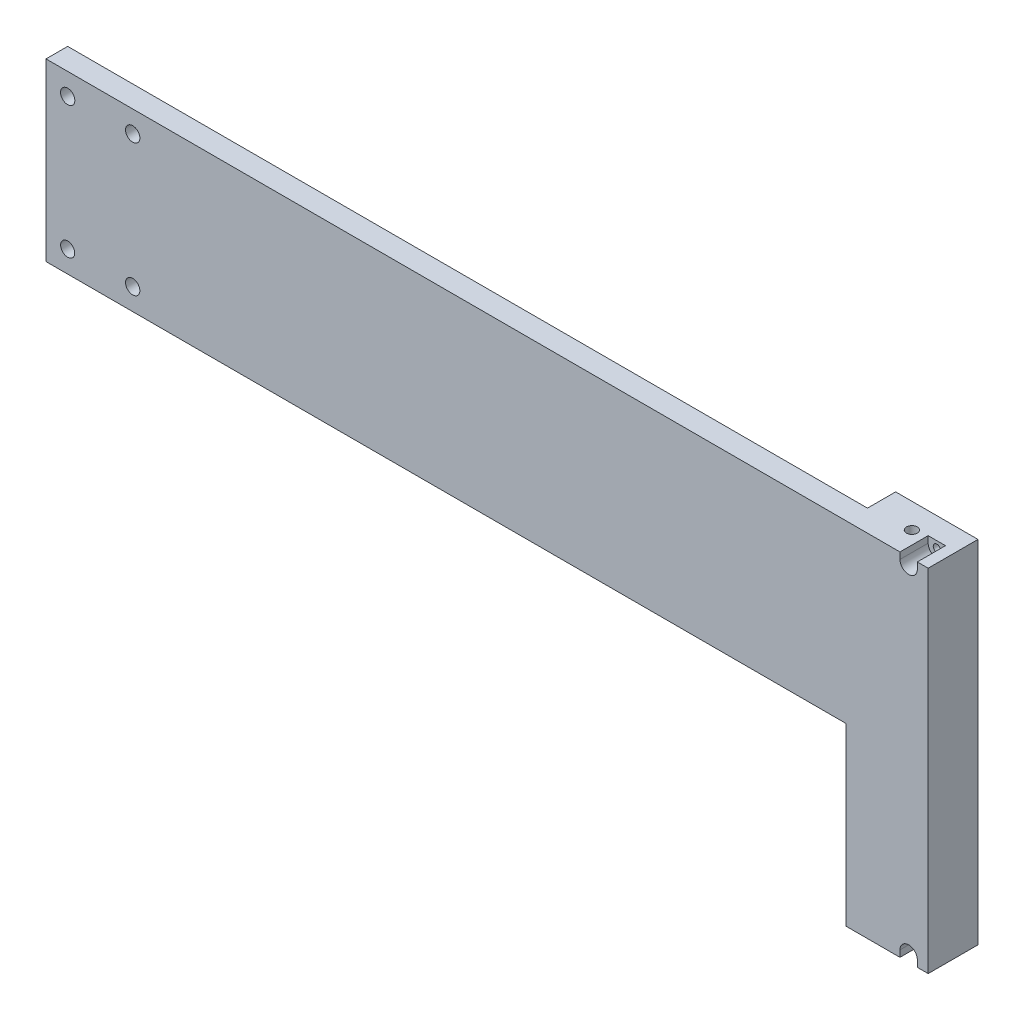
from build123d import *

# Parameters (mm, degrees)
SKETCH1_W           = 369
SKETCH1_H           = 81
BOSS_EXTRUDE1_DEPTH = 10
SKETCH2_W           = 23
SKETCH2_H           = 162
BOSS_EXTRUDE2_DEPTH = 38
SKETCH3_R           = 2.5
CUT_EXTRUDE1_DEPTH  = 163
SKETCH4_R           = 1.65
CUT_EXTRUDE2_DEPTH  = 24
CUT_EXTRUDE4_DEPTH  = 13
SKETCH6_R           = 3.3
SKETCH6_R_2         = 3.25
CUT_EXTRUDE5_DEPTH  = 13


with BuildPart() as part:
    # Sketch1 → Boss-Extrude1 (new body)
    with BuildSketch(Plane.XY):
        with Locations((184.5, 40.5)):
            Rectangle(SKETCH1_W, SKETCH1_H)
    extrude(amount=BOSS_EXTRUDE1_DEPTH)

    # Sketch2 → Boss-Extrude2 (add)
    with BuildSketch(Plane(origin=(369, 0, 0), x_dir=(0, 0, -1), z_dir=(1, 0, 0))):
        with Locations((1.5, 0)):
            Rectangle(SKETCH2_W, SKETCH2_H)
    extrude(amount=BOSS_EXTRUDE2_DEPTH)

    # Sketch3 → Cut-Extrude1 (cut, through all)
    with BuildSketch(Plane(origin=(0, 81, 0), x_dir=(1, 0, 0), z_dir=(0, 1, 0))):
        with Locations((388, 1.5)):
            Circle(SKETCH3_R)
    extrude(amount=-CUT_EXTRUDE1_DEPTH, mode=Mode.SUBTRACT)

    # Sketch4 → Cut-Extrude2 (cut, through all)
    with BuildSketch(Plane.XY.offset(10)):
        with Locations((398, -78)):
            Circle(SKETCH4_R)
        with Locations((398, 78)):
            Circle(SKETCH4_R)
    extrude(amount=-CUT_EXTRUDE2_DEPTH, mode=Mode.SUBTRACT)

    # Sketch5 → Cut-Extrude4 (cut)
    with BuildSketch(Plane.XY.offset(10)):
        with BuildLine():
            Line((394, 78), (394, 81))
            Line((394, 81), (402, 81))
            Line((402, 81), (402, 78))
            ThreePointArc((402, 78), (398, 74), (394, 78))
        make_face()
        with BuildLine():
            Line((394, -78), (394, -81))
            Line((394, -81), (402, -81))
            Line((402, -81), (402, -78))
            ThreePointArc((402, -78), (398, -74), (394, -78))
        make_face()
    extrude(amount=-CUT_EXTRUDE4_DEPTH, mode=Mode.SUBTRACT)

    # Sketch6 → Cut-Extrude5 (cut)
    with BuildSketch(Plane.XY.offset(10)):
        with Locations((10, 71)):
            Circle(SKETCH6_R)
        with Locations((40, 71)):
            Circle(SKETCH6_R)
        with Locations((40, 10)):
            Circle(SKETCH6_R)
        with Locations((10, 10)):
            Circle(SKETCH6_R_2)
    extrude(amount=-CUT_EXTRUDE5_DEPTH, mode=Mode.SUBTRACT)


solid = part.part
